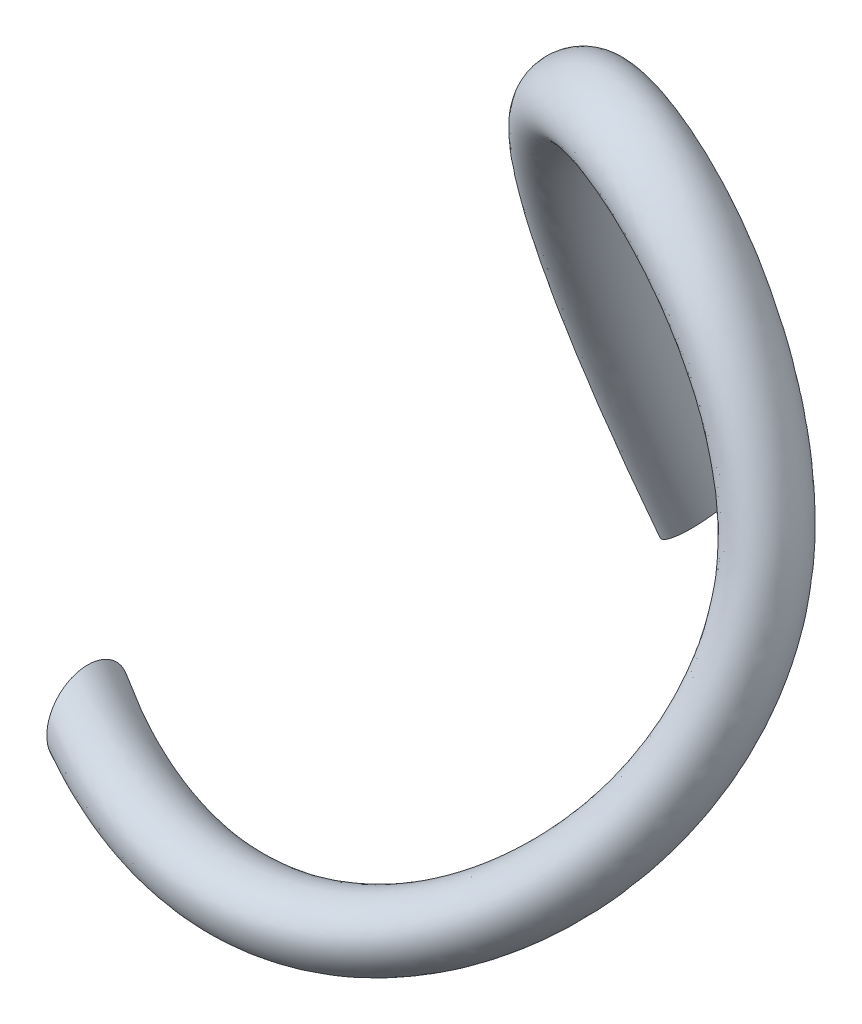
from build123d import *

# Parameters (mm, degrees)
SKETCH1_R   = 2
SKETCH1_R_2 = 1


with BuildPart() as part:
    # Sweep1: sweep along a curve in space
    with BuildLine() as sweep1_path:
        add(Edge.make_bspline(
            [(0, 0, 0), (13.187629303, -8.316592209, 4.602948669), (42.414414878, 16.663238408, -13.345590454), (5.354496925, 39.896969297, -7.154289197), (7.21766, 0.880408015, -23.076075845)],
            knots=[0, 0, 0, 0, 0.494444731, 1, 1, 1, 1], degree=3))
    # Sketch1 → Sweep1 (sweep)
    with BuildSketch(Plane(origin=(0, 0, 0), x_dir=(0, 0, -1), z_dir=(1, 0, 0))):
        Circle(SKETCH1_R)
        Circle(SKETCH1_R_2, mode=Mode.SUBTRACT)
    sweep(path=sweep1_path.line, is_frenet=True)


solid = part.part
